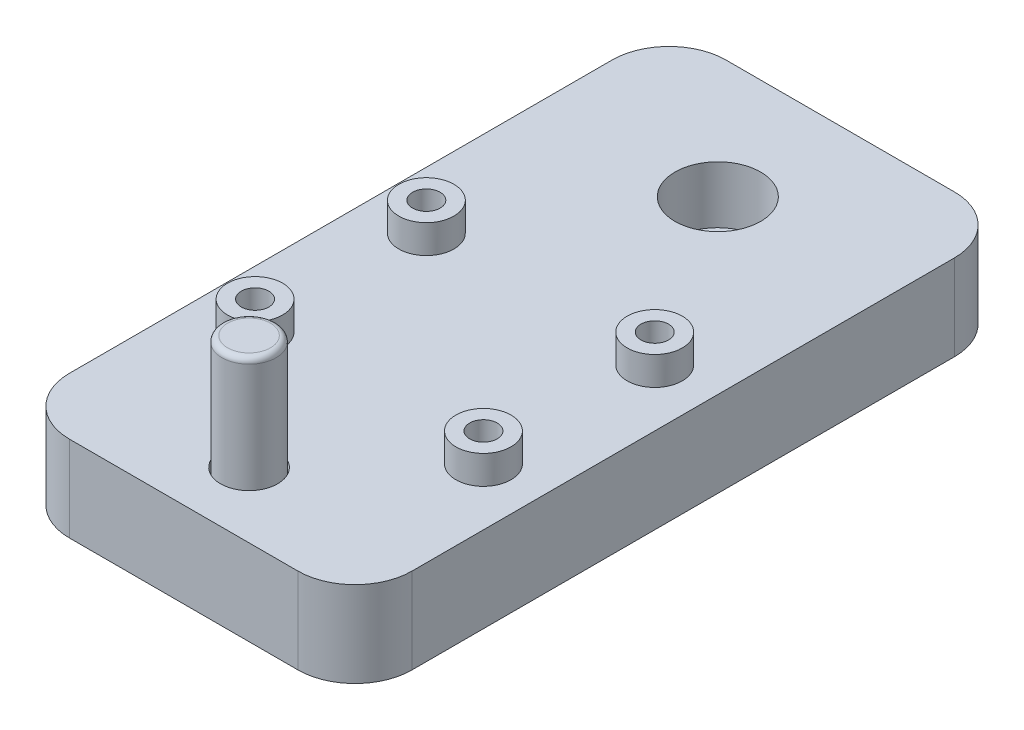
from build123d import *

# Parameters (mm, degrees)
SKETCH1_W           = 60
SKETCH1_H           = 115
BOSS_EXTRUDE1_DEPTH = 15
SKETCH2_R           = 7.5
SKETCH2_R_2         = 5
CUT_EXTRUDE1_DEPTH  = 10
SKETCH3_R           = 5
CUT_EXTRUDE2_DEPTH  = 14.5
SKETCH4_R           = 4.75
BOSS_EXTRUDE2_DEPTH = 30
FILLET1_R           = 1
FILLET2_R           = 10
SKETCH5_R           = 4.826
SKETCH5_R_2         = 2.413
BOSS_EXTRUDE3_DEPTH = 5


with BuildPart() as part:
    # Sketch1 → Boss-Extrude1 (new body)
    with BuildSketch(Plane(origin=(0, 0, 0), x_dir=(1, 0, 0), z_dir=(0, 1, 0))):
        with Locations((30, 57.5)):
            Rectangle(SKETCH1_W, SKETCH1_H)
    extrude(amount=BOSS_EXTRUDE1_DEPTH)

    # Sketch2 → Cut-Extrude1 (cut)
    with BuildSketch(Plane(origin=(0, 15, 0), x_dir=(1, 0, 0), z_dir=(0, 1, 0))):
        with Locations((30, 93.55)):
            Circle(SKETCH2_R)
        with Locations((30, 11.45)):
            Circle(SKETCH2_R_2)
    extrude(amount=-CUT_EXTRUDE1_DEPTH, mode=Mode.SUBTRACT)

    # Sketch3 → Cut-Extrude2 (cut)
    with BuildSketch(Plane(origin=(0, 0, 0), x_dir=(-1, 0, 0), z_dir=(0, -1, 0))):
        with Locations((-30, 57.5)):
            Circle(SKETCH3_R)
    extrude(amount=-CUT_EXTRUDE2_DEPTH, mode=Mode.SUBTRACT)

    # Sketch4 → Boss-Extrude2 (add)
    with BuildSketch(Plane(origin=(0, 5, 0), x_dir=(1, 0, 0), z_dir=(0, 1, 0))):
        with Locations((30, 11.45)):
            Circle(SKETCH4_R)
    extrude(amount=BOSS_EXTRUDE2_DEPTH)

    # Fillet1
    fillet1_edges = [part.edges().sort_by_distance(p)[0] for p in [
        (25.25, 35, -11.45),
    ]]
    fillet(fillet1_edges, radius=FILLET1_R)

    # Fillet2
    fillet2_edges = [part.edges().sort_by_distance(p)[0] for p in [
        (0, 7.5, -115),
        (60, 7.5, -115),
        (60, 7.5, 0),
        (0, 7.5, 0),
    ]]
    fillet(fillet2_edges, radius=FILLET2_R)

    # Sketch5 → Boss-Extrude3 (add)
    with BuildSketch(Plane(origin=(0, 15, 0), x_dir=(1, 0, 0), z_dir=(0, 1, 0))):
        with Locations((50, 62.5)):
            Circle(SKETCH5_R)
        with Locations((50, 62.5)):
            Circle(SKETCH5_R_2, mode=Mode.SUBTRACT)
        with Locations((50, 32.5)):
            Circle(SKETCH5_R)
        with Locations((50, 32.5)):
            Circle(SKETCH5_R_2, mode=Mode.SUBTRACT)
        with Locations((10, 32.5)):
            Circle(SKETCH5_R)
        with Locations((10, 32.5)):
            Circle(SKETCH5_R_2, mode=Mode.SUBTRACT)
        with Locations((10, 62.5)):
            Circle(SKETCH5_R)
        with Locations((10, 62.5)):
            Circle(SKETCH5_R_2, mode=Mode.SUBTRACT)
    extrude(amount=BOSS_EXTRUDE3_DEPTH)


solid = part.part
